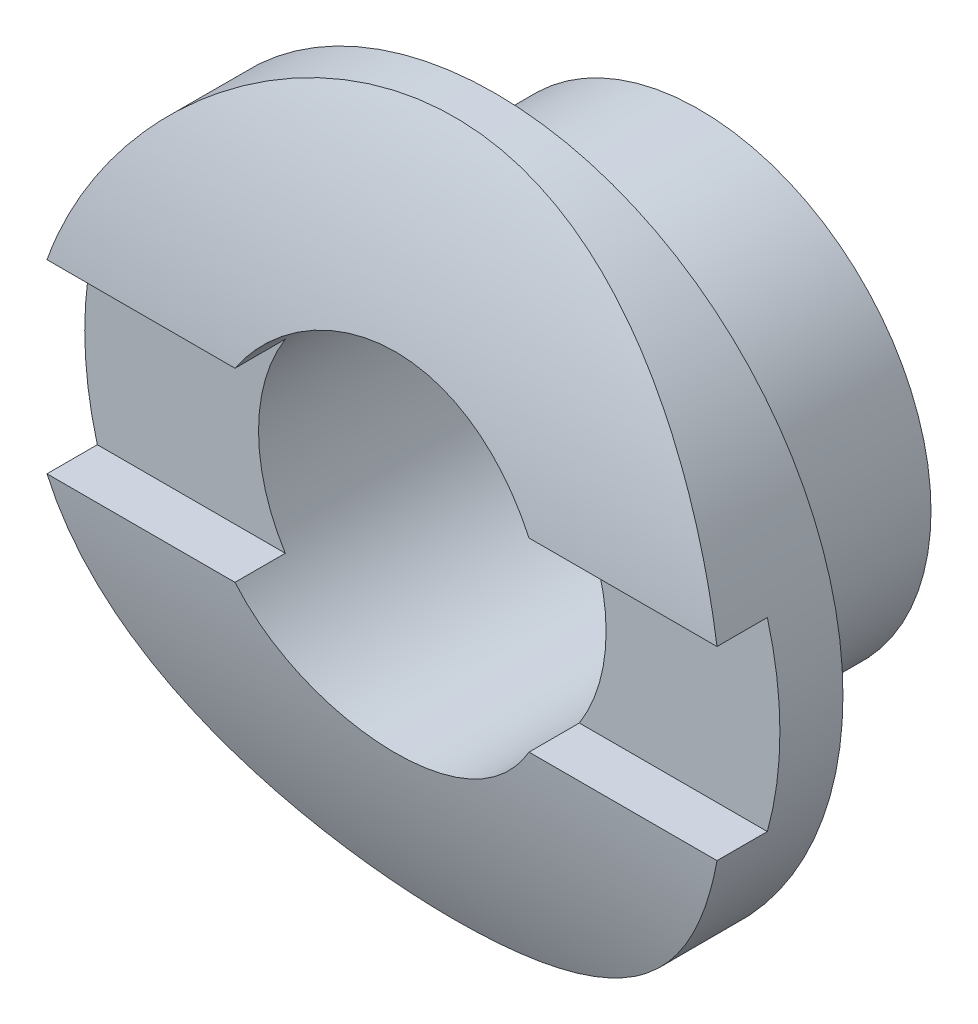
from build123d import *

# Parameters (mm, degrees)
SKETCH1_R               = 3.175
SKETCH1_R_2             = 2.38125
BOSS_EXTRUDE1_DEPTH     = 2.794
SKETCH2_R               = 4.7625
SKETCH2_R_2             = 2.38125
BOSS_EXTRUDE2_DEPTH     = 1.6256
SKETCH3_R               = 22.361166229
SKETCH3_R_2             = 11.176
CUT_EXTRUDE1_DEPTH      = 5.7625
CUT_EXTRUDE1_DEPTH_BACK = 5.7625
SKETCH4_W               = 0.762
SKETCH4_H               = 2.54
CUT_EXTRUDE2_DEPTH      = 5.7625001
CUT_EXTRUDE2_DEPTH_BACK = 5.7625001


with BuildPart() as part:
    # Sketch1 → Boss-Extrude1 (new body)
    with BuildSketch(Plane.XY):
        Circle(SKETCH1_R)
        Circle(SKETCH1_R_2, mode=Mode.SUBTRACT)
    extrude(amount=BOSS_EXTRUDE1_DEPTH)

    # Sketch2 → Boss-Extrude2 (add)
    with BuildSketch(Plane.XY.offset(2.794)):
        Circle(SKETCH2_R)
        Circle(SKETCH2_R_2, mode=Mode.SUBTRACT)
    extrude(amount=BOSS_EXTRUDE2_DEPTH)

    # Sketch3 → Cut-Extrude1 (cut, two sides)
    with BuildSketch(Plane(origin=(0, 0, 0), x_dir=(0, 0, -1), z_dir=(1, 0, 0))) as cut_extrude1_sk:
        with Locations((6.7564, 0)):
            Circle(SKETCH3_R)
        with Locations((6.7564, 0)):
            Circle(SKETCH3_R_2, mode=Mode.SUBTRACT)
    extrude(amount=CUT_EXTRUDE1_DEPTH, mode=Mode.SUBTRACT)
    extrude(cut_extrude1_sk.sketch, amount=-CUT_EXTRUDE1_DEPTH_BACK, mode=Mode.SUBTRACT)

    # Sketch4 → Cut-Extrude2 (cut, two sides)
    with BuildSketch(Plane(origin=(0, 0, 0), x_dir=(0, 0, -1), z_dir=(1, 0, 0))) as cut_extrude2_sk:
        with Locations((-4.0386, 0)):
            Rectangle(SKETCH4_W, SKETCH4_H)
    extrude(amount=CUT_EXTRUDE2_DEPTH, mode=Mode.SUBTRACT)
    extrude(cut_extrude2_sk.sketch, amount=-CUT_EXTRUDE2_DEPTH_BACK, mode=Mode.SUBTRACT)


solid = part.part
